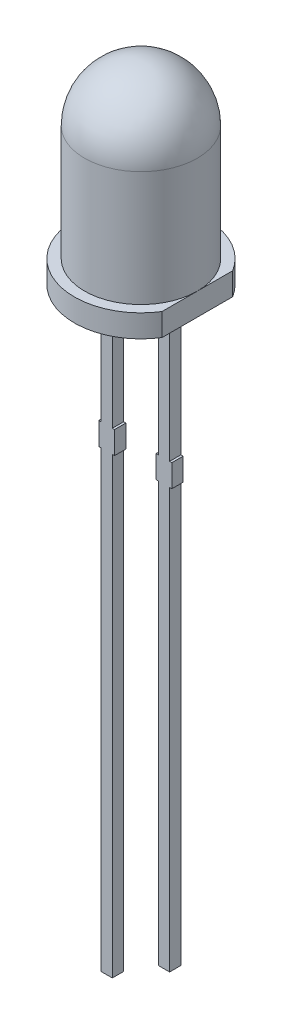
from build123d import *

# Parameters (mm, degrees)
EXTRUDE2_DEPTH      = 1
SKETCH3_3_W         = 0.5
SKETCH3_3_H         = 5.9
SKETCH3_3_H_2       = 1
SKETCH3_3_H_3       = 20.1
SKETCH3_3_W_2       = 0.1
SKETCH3_3_H_4       = 18.6
LEADS_EXTRUDE_DEPTH = 0.25


with BuildPart() as part:
    # Sketch2 → Extrude2 (new body)
    with BuildSketch(Plane(origin=(0, 0, 0), x_dir=(1, 0, 0), z_dir=(0, 1, 0))):
        with BuildLine():
            Line((2.5, -1.566045976), (2.5, 1.566045976))
            ThreePointArc((2.5, 1.566045976), (-2.95, 0), (2.5, -1.566045976))
        make_face()
    extrude(amount=EXTRUDE2_DEPTH)

    # Sketch3 → Revolve1 (revolve)
    with BuildSketch(Plane.XY):
        with BuildLine():
            Line((0, 8.6), (0, 1))
            Line((0, 1), (2.5, 1))
            Line((2.5, 1), (2.5, 6.1))
            ThreePointArc((2.5, 6.1), (1.767766953, 7.867766953), (0, 8.6))
        make_face()
    revolve(axis=Axis((0, 1, 0), (0, 1, 0)))


with BuildPart() as body_2:
    # Sketch3_3 → leads_extrude (new body, symmetric)
    with BuildSketch(Plane.XY):
        with Locations((-1.27, -2.95)):
            Rectangle(SKETCH3_3_W, SKETCH3_3_H)
        with Locations((-1.27, -6.4)):
            Rectangle(SKETCH3_3_W, SKETCH3_3_H_2)
        with Locations((-1.27, -16.95)):
            Rectangle(SKETCH3_3_W, SKETCH3_3_H_3)
        with Locations((-0.97, -6.4)):
            Rectangle(SKETCH3_3_W_2, SKETCH3_3_H_2)
        with Locations((-1.57, -6.4)):
            Rectangle(SKETCH3_3_W_2, SKETCH3_3_H_2)
        with Locations((1.27, -2.95)):
            Rectangle(SKETCH3_3_W, SKETCH3_3_H)
        with Locations((1.27, -6.4)):
            Rectangle(SKETCH3_3_W, SKETCH3_3_H_2)
        with Locations((0.97, -6.4)):
            Rectangle(SKETCH3_3_W_2, SKETCH3_3_H_2)
        with Locations((1.57, -6.4)):
            Rectangle(SKETCH3_3_W_2, SKETCH3_3_H_2)
        with Locations((1.27, -16.2)):
            Rectangle(SKETCH3_3_W, SKETCH3_3_H_4)
    extrude(amount=LEADS_EXTRUDE_DEPTH, both=True)


solid = Compound([part.part, body_2.part])
